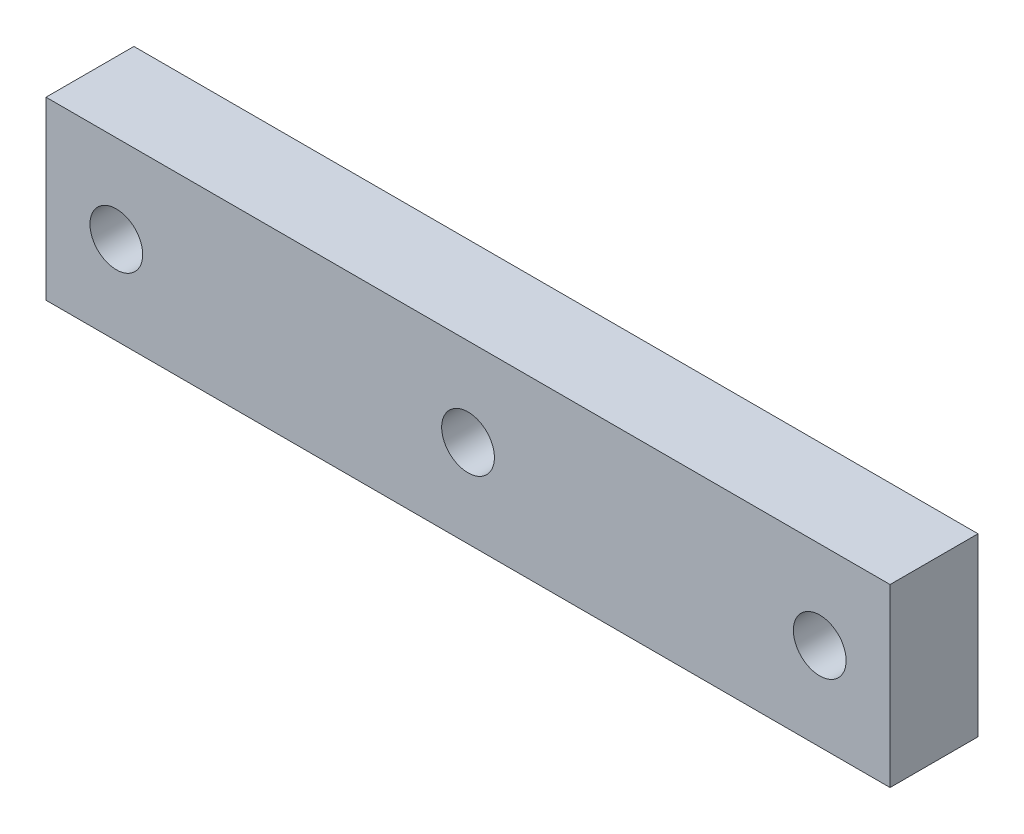
from build123d import *

# Parameters (mm, degrees)
CROQUIS1_W              = 336
CROQUIS1_H              = 70
CROQUIS1_R              = 10.5
SALIENTE_EXTRUIR1_DEPTH = 35


with BuildPart() as part:
    # Croquis1 → Saliente-Extruir1 (new body)
    with BuildSketch(Plane.XY):
        with Locations((168, 35)):
            Rectangle(CROQUIS1_W, CROQUIS1_H)
        with Locations((308, 35)):
            Circle(CROQUIS1_R, mode=Mode.SUBTRACT)
        with Locations((168, 35)):
            Circle(CROQUIS1_R, mode=Mode.SUBTRACT)
        with Locations((28, 35)):
            Circle(CROQUIS1_R, mode=Mode.SUBTRACT)
    extrude(amount=SALIENTE_EXTRUIR1_DEPTH)


solid = part.part
